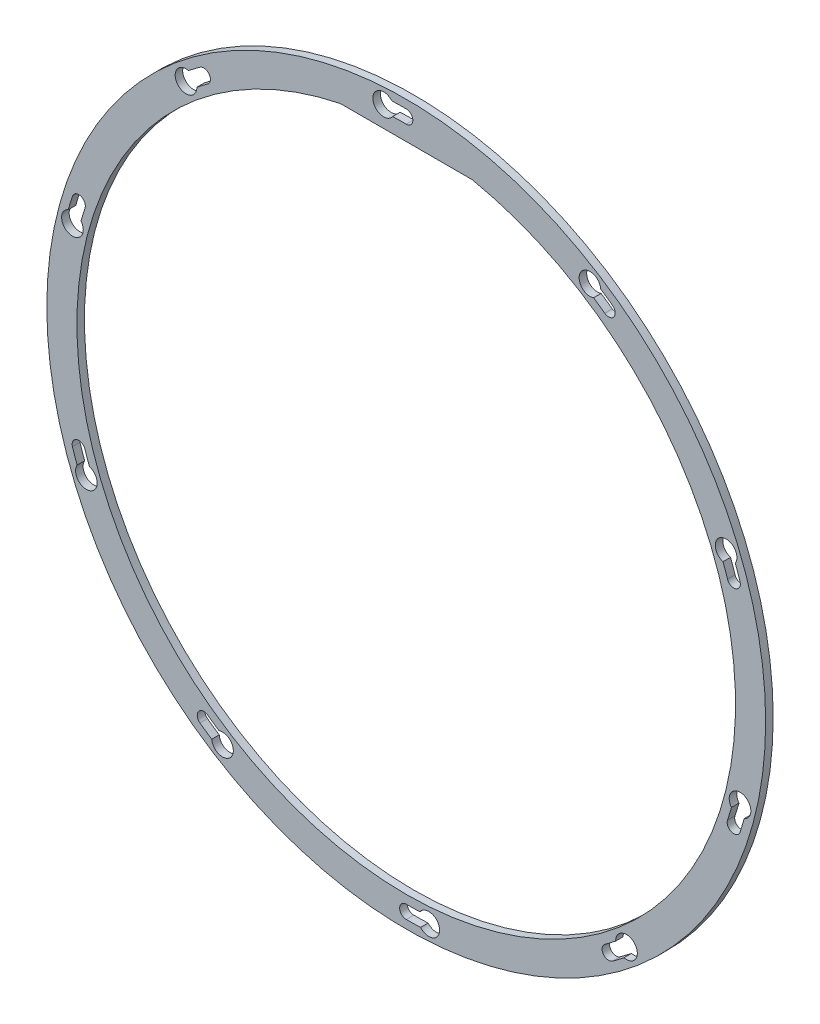
from build123d import *

# Parameters (mm, degrees)
SKETCH1_R            = 191
BOSS_EXTRUDE1_DEPTH  = 4
M6_CLEARANCE_HOLE1_D = 7
CUT_EXTRUDE3_DEPTH   = 5
CIRPATTERN1_COUNT    = 10


with BuildPart() as part:
    # Sketch1 → Boss-Extrude1 (new body)
    with BuildSketch(Plane.XY):
        Circle(SKETCH1_R)
        with BuildLine():
            Line((-35, 171.464281995), (35, 171.464281995))
            ThreePointArc((35, 171.464281995), (0, -175), (-35, 171.464281995))
        make_face(mode=Mode.SUBTRACT)
    extrude(amount=BOSS_EXTRUDE1_DEPTH)

    # M6 Clearance Hole1 (through all)
    with Locations(Plane.XY.offset(4)):
        with Locations((0, 183)):
            m6_clearance_hole1 = Hole(M6_CLEARANCE_HOLE1_D / 2)

    # Sketch4 → Cut-Extrude3 (cut, through all)
    with BuildSketch(Plane.XY.offset(4)):
        with BuildLine():
            Line((0, 186.5), (0, 179.5))
            ThreePointArc((0, 179.5), (-3.626876902, 179.463354933), (-7.252272944, 179.353434696))
            ThreePointArc((-7.252272944, 179.353434696), (-17.735437822, 182.301261264), (-7.623966656, 186.344104099))
            ThreePointArc((-7.623966656, 186.344104099), (-3.81278019, 186.461021952), (0, 186.5))
        make_face()
    cut_extrude3 = extrude(amount=-CUT_EXTRUDE3_DEPTH, mode=Mode.SUBTRACT)

    # CirPattern1: M6 Clearance Hole1, Cut-Extrude3 ×10 about axis
    cirpattern1_axis = Axis((0, 0, 0), (0, 0, 1))
    for i in range(1, CIRPATTERN1_COUNT):
        add(m6_clearance_hole1.rotate(cirpattern1_axis, i * 360 / CIRPATTERN1_COUNT), mode=Mode.SUBTRACT)
        add(cut_extrude3.rotate(cirpattern1_axis, i * 360 / CIRPATTERN1_COUNT), mode=Mode.SUBTRACT)


solid = part.part
